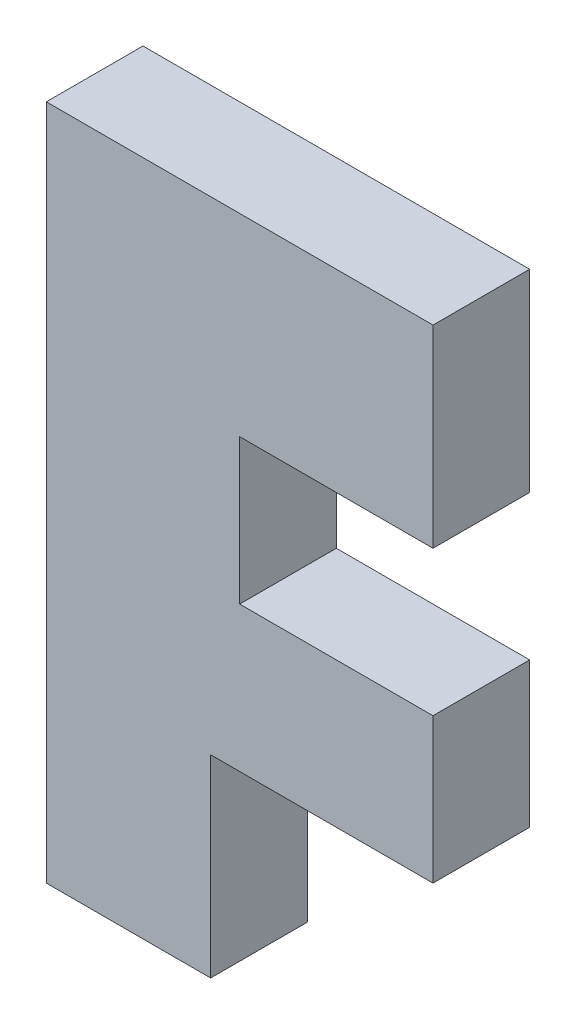
from build123d import *

# Parameters (mm, degrees)
BOSS_EXTRUDE1_DEPTH = 12.7


with BuildPart() as part:
    # Sketch1 → Boss-Extrude1 (new body)
    with BuildSketch(Plane.XY):
        Polygon((0, 0), (0, 88.9), (50.8, 88.9), (50.8, 63.5), (25.4, 63.5), (25.4, 44.45), (50.8, 44.45), (50.8, 25.4), (21.59, 25.4), (21.59, 0), align=None)
    extrude(amount=BOSS_EXTRUDE1_DEPTH)


solid = part.part
